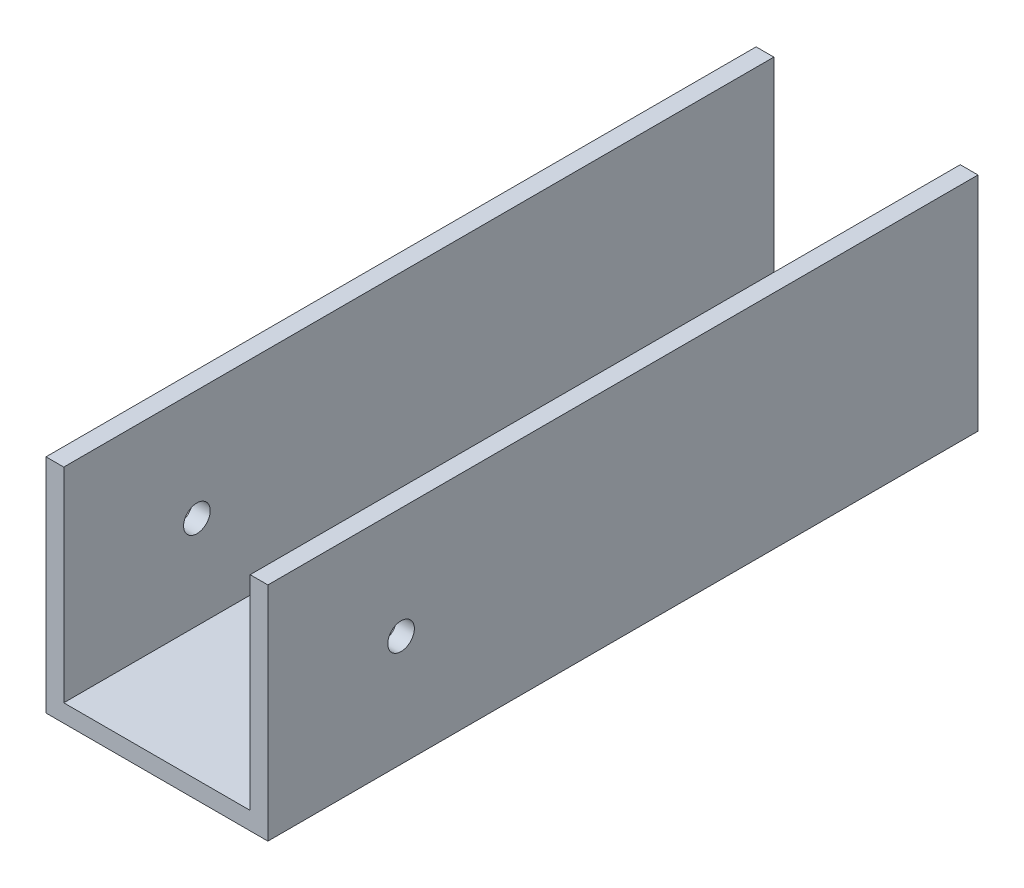
from build123d import *

# Parameters (mm, degrees)
BOSS_EXTRUDE1_DEPTH = 80
SKETCH3_R           = 1.5
CUT_EXTRUDE1_DEPTH  = 25
CUT_EXTRUDE2_REACH  = 27
SKETCH4_R           = 3


with BuildPart() as part:
    # Sketch2 → Boss-Extrude1 (new body)
    with BuildSketch(Plane.XY):
        Polygon((23, 25), (25, 25), (25, 0), (0, 0), (0, 25), (2, 25), (2, 2), (23, 2), align=None)
    extrude(amount=BOSS_EXTRUDE1_DEPTH)

    # Sketch3 → Cut-Extrude1 (cut)
    with BuildSketch(Plane(origin=(25, 0, 0), x_dir=(0, 0, -1), z_dir=(1, 0, 0))):
        with Locations((-65, 12.5)):
            Circle(SKETCH3_R)
    extrude(amount=-CUT_EXTRUDE1_DEPTH, mode=Mode.SUBTRACT)

    # Sketch4 → Cut-Extrude2 (cut, up to next)
    with BuildSketch(Plane.XZ, mode=Mode.PRIVATE) as cut_extrude2_sk1:
        with Locations((12.5, 60)):
            Circle(SKETCH4_R)
    cut_extrude2_tool1 = extrude(cut_extrude2_sk1.sketch, amount=-CUT_EXTRUDE2_REACH, mode=Mode.PRIVATE) & part.part
    add(cut_extrude2_tool1.solids().sort_by_distance((12.5, 0, 60))[0], mode=Mode.SUBTRACT)
    # Sketch4 → Cut-Extrude2 (cut, up to next)
    with BuildSketch(Plane.XZ, mode=Mode.PRIVATE) as cut_extrude2_sk2:
        with Locations((12.5, 20)):
            Circle(SKETCH4_R)
    cut_extrude2_tool2 = extrude(cut_extrude2_sk2.sketch, amount=-CUT_EXTRUDE2_REACH, mode=Mode.PRIVATE) & part.part
    add(cut_extrude2_tool2.solids().sort_by_distance((12.5, 0, 20))[0], mode=Mode.SUBTRACT)


solid = part.part
